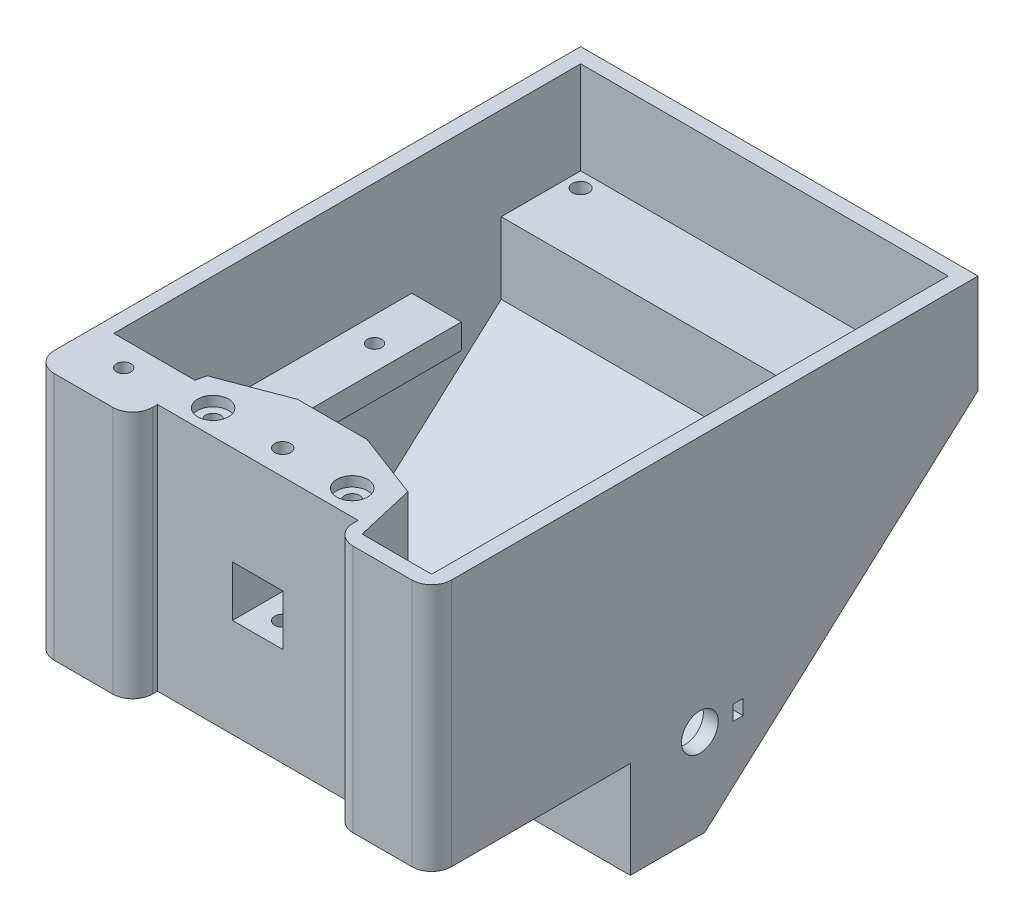
from build123d import *

# Parameters (mm, degrees)
BOSS_EXTRUDE1_DEPTH = 80
SHELL1_T            = -3
SKETCH3_W           = 46
SKETCH3_H           = 47
BOSS_EXTRUDE2_DEPTH = 17
SKETCH4_W           = 10.2
SKETCH4_H           = 10.2
CUT_EXTRUDE1_DEPTH  = 20
SKETCH6_W           = 15
SKETCH6_H           = 12.8
CUT_EXTRUDE2_DEPTH  = 3
SKETCH7_W           = 40.4
SKETCH7_H           = 50
CUT_EXTRUDE3_DEPTH  = 5
FILLET1_R           = 4
CUT_EXTRUDE7_DEPTH  = 47
SKETCH13_R          = 1.5
CUT_EXTRUDE8_DEPTH  = 25
SKETCH14_R          = 3.1
CUT_EXTRUDE9_DEPTH  = 2
SKETCH17_W          = 45
SKETCH17_H          = 5
BOSS_EXTRUDE5_DEPTH = 74
CUT_EXTRUDE10_REACH = 48.51
SKETCH18_W          = 54
SKETCH18_H          = 45
CUT_EXTRUDE11_REACH = 48.51
SKETCH19_R          = 1.45
BOSS_EXTRUDE6_DEPTH = 47
SKETCH22_R          = 1.45
CUT_EXTRUDE12_DEPTH = 70.509632224
CUT_EXTRUDE13_REACH = 82
SKETCH24_R          = 3.7
SKETCH24_W          = 2
SKETCH24_H          = 3
BOSS_EXTRUDE7_DEPTH = 74
SKETCH27_R          = 1.65
CUT_EXTRUDE14_DEPTH = 10
CUT_EXTRUDE15_START = -3
CUT_EXTRUDE15_DEPTH = 32
CUT_EXTRUDE16_DEPTH = 30
BOSS_EXTRUDE8_DEPTH = 20
SKETCH31_R          = 1.5
CUT_EXTRUDE17_DEPTH = 43.509632224
CUT_EXTRUDE18_DEPTH = 15
CUT_EXTRUDE19_REACH = 48.51
SKETCH33_W          = 10
SKETCH33_H          = 5
SKETCH34_R          = 1.6
CUT_EXTRUDE20_DEPTH = 70.509632224
CUT_EXTRUDE22_DEPTH = 14
CUT_EXTRUDE24_REACH = 5
SKETCH40_R          = 3.7
SKETCH40_W          = 2
SKETCH40_H          = 3


with BuildPart() as part:
    # Sketch2 → Boss-Extrude1 (new body)
    with BuildSketch(Plane(origin=(0, 0, 0), x_dir=(0, 0, -1), z_dir=(1, 0, 0))):
        Polygon((-27.320490368, 20.998248687), (-27.320490368, -29.001751313), (12.679509632, -29.001751313), (12.679509632, -48.511383538), (27.679509632, -48.511383538), (82.679509632, 0.998248687), (82.679509632, 20.998248687), align=None)
    extrude(amount=BOSS_EXTRUDE1_DEPTH)

    # Shell1
    shell1_openings = [part.faces().sort_by_distance(p)[0] for p in [
        (40, 20.998248687, -27.679509632),
    ]]
    offset(amount=SHELL1_T, openings=shell1_openings, kind=Kind.INTERSECTION)

    # Sketch3 → Boss-Extrude2 (add)
    with BuildSketch(Plane(origin=(0, 0, 24.320490368), x_dir=(-1, 0, 0), z_dir=(0, 0, -1))):
        with Locations((-40, -2.501751313)):
            Rectangle(SKETCH3_W, SKETCH3_H)
    extrude(amount=BOSS_EXTRUDE2_DEPTH)

    # Sketch4 → Cut-Extrude1 (cut)
    with BuildSketch(Plane.XY.offset(27.320490368)):
        with Locations((40, -4.001751313)):
            Rectangle(SKETCH4_W, SKETCH4_H)
    extrude(amount=-CUT_EXTRUDE1_DEPTH, mode=Mode.SUBTRACT)

    # Sketch6 → Cut-Extrude2 (cut)
    with BuildSketch(Plane.XZ.offset(29.001751313)):
        with Locations((51.5, 0.920490368)):
            Rectangle(SKETCH6_W, SKETCH6_H)
        with Locations((28.5, 0.920490368)):
            Rectangle(SKETCH6_W, SKETCH6_H)
    extrude(amount=-CUT_EXTRUDE2_DEPTH, mode=Mode.SUBTRACT)

    # Sketch7 → Cut-Extrude3 (cut)
    with BuildSketch(Plane.XY.offset(27.320490368)):
        with Locations((40, -4.001751313)):
            Rectangle(SKETCH7_W, SKETCH7_H)
    extrude(amount=-CUT_EXTRUDE3_DEPTH, mode=Mode.SUBTRACT)

    # Fillet1
    fillet1_edges = [part.edges().sort_by_distance(p)[0] for p in [
        (19.8, -4.001751313, 27.320490368),
        (60.2, -4.001751313, 27.320490368),
        (80, -4.001751313, 27.320490368),
        (0, -4.001751313, 27.320490368),
    ]]
    fillet(fillet1_edges, radius=FILLET1_R)

    # Sketch12 → Cut-Extrude7 (cut)
    with BuildSketch(Plane(origin=(0, 20.998248687, 0), x_dir=(1, 0, 0), z_dir=(0, 1, 0))):
        Polygon((33, -7.320490368), (19.8, -12.320490368), (17, -24.320490368), (17, -7.320490368), align=None)
        Polygon((47, -7.320490368), (63, -7.320490368), (63, -24.320490368), (60.2, -12.320490368), align=None)
    extrude(amount=-CUT_EXTRUDE7_DEPTH, mode=Mode.SUBTRACT)

    # Sketch13 → Cut-Extrude8 (cut)
    with BuildSketch(Plane(origin=(0, 20.998248687, 0), x_dir=(1, 0, 0), z_dir=(0, 1, 0))):
        with Locations((26, -17.320490368)):
            Circle(SKETCH13_R)
        with Locations((54, -17.320490368)):
            Circle(SKETCH13_R)
    extrude(amount=-CUT_EXTRUDE8_DEPTH, mode=Mode.SUBTRACT)

    # Sketch14 → Cut-Extrude9 (cut)
    with BuildSketch(Plane(origin=(0, 20.998248687, 0), x_dir=(1, 0, 0), z_dir=(0, 1, 0))):
        with Locations((26, -17.320490368)):
            Circle(SKETCH14_R)
        with Locations((54, -17.320490368)):
            Circle(SKETCH14_R)
    extrude(amount=-CUT_EXTRUDE9_DEPTH, mode=Mode.SUBTRACT)

    # Sketch17 → Boss-Extrude5 (add)
    with BuildSketch(Plane.ZY.offset(-77)):
        with Locations((-23.179509632, -4.501751313)):
            Rectangle(SKETCH17_W, SKETCH17_H)
    extrude(amount=BOSS_EXTRUDE5_DEPTH)

    # Sketch18 → Cut-Extrude10 (cut, up to next)
    with BuildSketch(Plane(origin=(0, -2.001751313, 0), x_dir=(1, 0, 0), z_dir=(0, 1, 0)), mode=Mode.PRIVATE) as cut_extrude10_sk1:
        with Locations((40, 23.179509632)):
            Rectangle(SKETCH18_W, SKETCH18_H)
    cut_extrude10_tool1 = extrude(cut_extrude10_sk1.sketch, amount=-CUT_EXTRUDE10_REACH, mode=Mode.PRIVATE) & part.part
    add(cut_extrude10_tool1.solids().sort_by_distance((40, -2.001751, -23.17951))[0], mode=Mode.SUBTRACT)

    # Sketch19 → Cut-Extrude11 (cut, up to next)
    with BuildSketch(Plane(origin=(0, -2.001751313, 0), x_dir=(1, 0, 0), z_dir=(0, 1, 0)), mode=Mode.PRIVATE) as cut_extrude11_sk1:
        with Locations((72, 37.179509632)):
            Circle(SKETCH19_R)
    cut_extrude11_tool1 = extrude(cut_extrude11_sk1.sketch, amount=-CUT_EXTRUDE11_REACH, mode=Mode.PRIVATE) & part.part
    add(cut_extrude11_tool1.solids().sort_by_distance((72, -2.001751, -37.17951))[0], mode=Mode.SUBTRACT)
    # Sketch19 → Cut-Extrude11 (cut, up to next)
    with BuildSketch(Plane(origin=(0, -2.001751313, 0), x_dir=(1, 0, 0), z_dir=(0, 1, 0)), mode=Mode.PRIVATE) as cut_extrude11_sk2:
        with Locations((72, 6.179509632)):
            Circle(SKETCH19_R)
    cut_extrude11_tool2 = extrude(cut_extrude11_sk2.sketch, amount=-CUT_EXTRUDE11_REACH, mode=Mode.PRIVATE) & part.part
    add(cut_extrude11_tool2.solids().sort_by_distance((72, -2.001751, -6.17951))[0], mode=Mode.SUBTRACT)
    # Sketch19 → Cut-Extrude11 (cut, up to next)
    with BuildSketch(Plane(origin=(0, -2.001751313, 0), x_dir=(1, 0, 0), z_dir=(0, 1, 0)), mode=Mode.PRIVATE) as cut_extrude11_sk3:
        with Locations((8, 33.179509632)):
            Circle(SKETCH19_R)
    cut_extrude11_tool3 = extrude(cut_extrude11_sk3.sketch, amount=-CUT_EXTRUDE11_REACH, mode=Mode.PRIVATE) & part.part
    add(cut_extrude11_tool3.solids().sort_by_distance((8, -2.001751, -33.17951))[0], mode=Mode.SUBTRACT)
    # Sketch19 → Cut-Extrude11 (cut, up to next)
    with BuildSketch(Plane(origin=(0, -2.001751313, 0), x_dir=(1, 0, 0), z_dir=(0, 1, 0)), mode=Mode.PRIVATE) as cut_extrude11_sk4:
        with Locations((8, 6.179509632)):
            Circle(SKETCH19_R)
    cut_extrude11_tool4 = extrude(cut_extrude11_sk4.sketch, amount=-CUT_EXTRUDE11_REACH, mode=Mode.PRIVATE) & part.part
    add(cut_extrude11_tool4.solids().sort_by_distance((8, -2.001751, -6.17951))[0], mode=Mode.SUBTRACT)

    # Sketch21 → Boss-Extrude6 (add)
    with BuildSketch(Plane(origin=(0, -26.001751313, 0), x_dir=(1, 0, 0), z_dir=(0, 1, 0))):
        Polygon((3, -24.320490368), (3, -14.320490368), (19.333333333, -14.320490368), (17, -24.320490368), align=None)
    extrude(amount=BOSS_EXTRUDE6_DEPTH)

    # Sketch22 → Cut-Extrude12 (cut, through all)
    with BuildSketch(Plane(origin=(0, 20.998248687, 0), x_dir=(1, 0, 0), z_dir=(0, 1, 0))):
        with Locations((10, -19.320490368)):
            Circle(SKETCH22_R)
    extrude(amount=-CUT_EXTRUDE12_DEPTH, mode=Mode.SUBTRACT)

    # Sketch24 → Cut-Extrude13 (cut, up to next)
    with BuildSketch(Plane(origin=(80, 0, 0), x_dir=(0, 0, -1), z_dir=(1, 0, 0)), mode=Mode.PRIVATE) as cut_extrude13_sk1:
        with Locations((26.679509632, -30.511383538)):
            Circle(SKETCH24_R)
    cut_extrude13_tool1 = extrude(cut_extrude13_sk1.sketch, amount=-CUT_EXTRUDE13_REACH, mode=Mode.PRIVATE) & part.part
    add(cut_extrude13_tool1.solids().sort_by_distance((80, -30.511384, -26.67951))[0], mode=Mode.SUBTRACT)
    # Sketch24 → Cut-Extrude13 (cut, up to next)
    with BuildSketch(Plane(origin=(80, 0, 0), x_dir=(0, 0, -1), z_dir=(1, 0, 0)), mode=Mode.PRIVATE) as cut_extrude13_sk2:
        with Locations((34.379509632, -30.511383538)):
            Rectangle(SKETCH24_W, SKETCH24_H)
    cut_extrude13_tool2 = extrude(cut_extrude13_sk2.sketch, amount=-CUT_EXTRUDE13_REACH, mode=Mode.PRIVATE) & part.part
    add(cut_extrude13_tool2.solids().sort_by_distance((80, -30.511384, -34.37951))[0], mode=Mode.SUBTRACT)

    # Sketch26 → Boss-Extrude7 (add)
    with BuildSketch(Plane(origin=(3, 0, 0), x_dir=(0, 0, -1), z_dir=(1, 0, 0))):
        Polygon((79.679509632, 2.334161996), (63.679509632, 2.334161996), (63.679509632, -12.068640106), align=None)
    extrude(amount=BOSS_EXTRUDE7_DEPTH)

    # Sketch27 → Cut-Extrude14 (cut)
    with BuildSketch(Plane(origin=(0, 2.334161996, 0), x_dir=(1, 0, 0), z_dir=(0, 1, 0))):
        with Locations((6, 76.679509632)):
            Circle(SKETCH27_R)
        with Locations((74, 76.679509632)):
            Circle(SKETCH27_R)
    extrude(amount=-CUT_EXTRUDE14_DEPTH, mode=Mode.SUBTRACT)

    # Sketch28 → Cut-Extrude15 (cut)
    with BuildSketch(Plane(origin=(0, 2.334161996, 0), x_dir=(1, 0, 0), z_dir=(0, 1, 0)).offset(CUT_EXTRUDE15_START)):
        Polygon((74, 79.929509632), (71.185417438, 78.304509632), (71.185417438, 75.054509632), (74, 73.429509632), (76.814582562, 75.054509632), (76.814582562, 78.304509632), align=None)
        Polygon((6, 73.429509632), (8.814582562, 75.054509632), (8.814582562, 78.304509632), (6, 79.929509632), (3.185417438, 78.304509632), (3.185417438, 75.054509632), align=None)
    extrude(amount=-CUT_EXTRUDE15_DEPTH, mode=Mode.SUBTRACT)

    # Sketch29 → Cut-Extrude16 (cut)
    with BuildSketch(Plane.XZ.offset(29.001751313)):
        Polygon((7.185417438, 17.695490368), (10, 16.070490368), (12.814582562, 17.695490368), (12.814582562, 20.945490368), (10, 22.570490368), (7.185417438, 20.945490368), align=None)
    extrude(amount=-CUT_EXTRUDE16_DEPTH, mode=Mode.SUBTRACT)

    # Sketch30 → Boss-Extrude8 (add)
    with BuildSketch(Plane(origin=(0, -26.001751313, 0), x_dir=(1, 0, 0), z_dir=(0, 1, 0))):
        Polygon((77, -24.320490368), (63, -24.320490368), (60.2, -12.320490368), (77, -12.320490368), align=None)
    extrude(amount=BOSS_EXTRUDE8_DEPTH)

    # Sketch31 → Cut-Extrude17 (cut, through all)
    with BuildSketch(Plane(origin=(0, -6.001751313, 0), x_dir=(1, 0, 0), z_dir=(0, 1, 0))):
        with Locations((72, -21.320490368)):
            Circle(SKETCH31_R)
    extrude(amount=-CUT_EXTRUDE17_DEPTH, mode=Mode.SUBTRACT)

    # Sketch32 → Cut-Extrude18 (cut)
    with BuildSketch(Plane.XZ.offset(29.001751313)):
        Polygon((72, 24.570490368), (69.185417438, 22.945490368), (69.185417438, 19.695490368), (72, 18.070490368), (74.814582562, 19.695490368), (74.814582562, 22.945490368), align=None)
    extrude(amount=-CUT_EXTRUDE18_DEPTH, mode=Mode.SUBTRACT)

    # Sketch33 → Cut-Extrude19 (cut, up to next)
    with BuildSketch(Plane(origin=(0, -2.001751313, 0), x_dir=(1, 0, 0), z_dir=(0, 1, 0)), mode=Mode.PRIVATE) as cut_extrude19_sk1:
        with Locations((72, 43.179509632)):
            Rectangle(SKETCH33_W, SKETCH33_H)
    cut_extrude19_tool1 = extrude(cut_extrude19_sk1.sketch, amount=-CUT_EXTRUDE19_REACH, mode=Mode.PRIVATE) & part.part
    add(cut_extrude19_tool1.solids().sort_by_distance((72, -2.001751, -43.17951))[0], mode=Mode.SUBTRACT)

    # Sketch34 → Cut-Extrude20 (cut, through all)
    with BuildSketch(Plane(origin=(0, 20.998248687, 0), x_dir=(1, 0, 0), z_dir=(0, 1, 0))):
        with Locations((40, -17.320490368)):
            Circle(SKETCH34_R)
    extrude(amount=-CUT_EXTRUDE20_DEPTH, mode=Mode.SUBTRACT)

    # Sketch36 → Cut-Extrude22 (cut)
    with BuildSketch(Plane.XZ.offset(29.001751313)):
        Polygon((38.375, 20.13507293), (36.75, 17.320490368), (38.375, 14.505907805), (41.625, 14.505907805), (43.25, 17.320490368), (41.625, 20.13507293), align=None)
    extrude(amount=-CUT_EXTRUDE22_DEPTH, mode=Mode.SUBTRACT)

    # Sketch40 → Cut-Extrude24 (cut, up to next)
    with BuildSketch(Plane(origin=(3, 0, 0), x_dir=(0, 0, -1), z_dir=(1, 0, 0)), mode=Mode.PRIVATE) as cut_extrude24_sk1:
        with Locations((26.679509632, -30.511383538)):
            Circle(SKETCH40_R)
    cut_extrude24_tool1 = extrude(cut_extrude24_sk1.sketch, amount=-CUT_EXTRUDE24_REACH, mode=Mode.PRIVATE) & part.part
    add(cut_extrude24_tool1.solids().sort_by_distance((3, -30.511384, -26.67951))[0], mode=Mode.SUBTRACT)
    # Sketch40 → Cut-Extrude24 (cut, up to next)
    with BuildSketch(Plane(origin=(3, 0, 0), x_dir=(0, 0, -1), z_dir=(1, 0, 0)), mode=Mode.PRIVATE) as cut_extrude24_sk2:
        with Locations((18.979509632, -30.511383538)):
            Rectangle(SKETCH40_W, SKETCH40_H)
    cut_extrude24_tool2 = extrude(cut_extrude24_sk2.sketch, amount=-CUT_EXTRUDE24_REACH, mode=Mode.PRIVATE) & part.part
    add(cut_extrude24_tool2.solids().sort_by_distance((3, -30.511384, -18.97951))[0], mode=Mode.SUBTRACT)


solid = part.part
